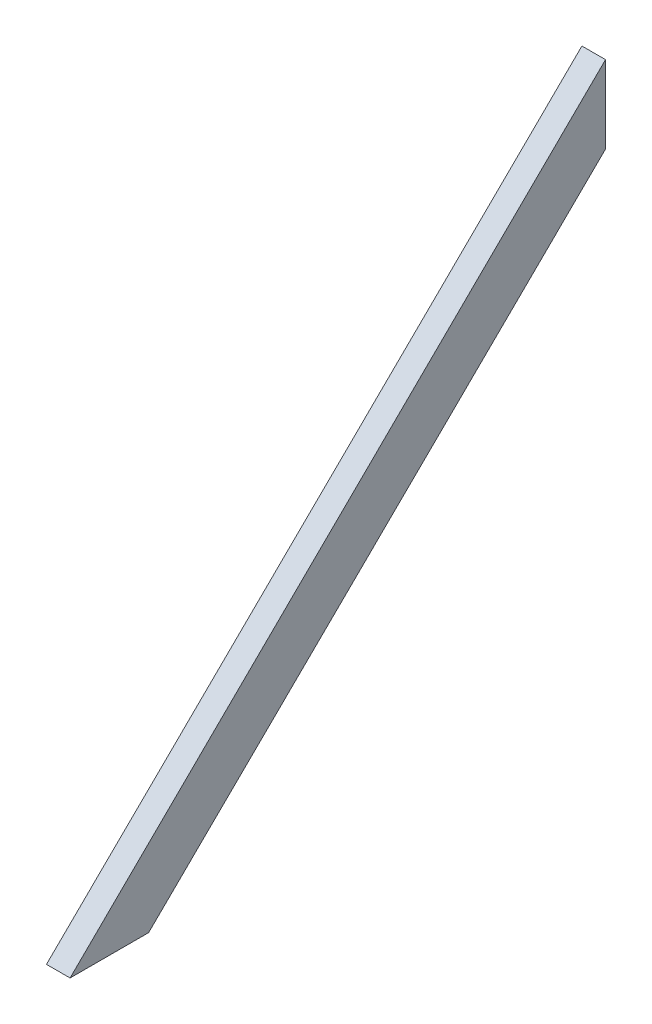
from build123d import *

# Parameters (mm, degrees)
BOSS_EXTRUDE1_DEPTH = 38.1


with BuildPart() as part:
    # Sketch1 → Boss-Extrude1 (new body)
    with BuildSketch(Plane(origin=(0, 0, 0), x_dir=(0, 0, -1), z_dir=(1, 0, 0))):
        Polygon((-431.8, -425.45), (-305.134703691, -425.45), (431.8, 300.647428637), (431.8, 425.45), align=None)
    extrude(amount=BOSS_EXTRUDE1_DEPTH)


solid = part.part
